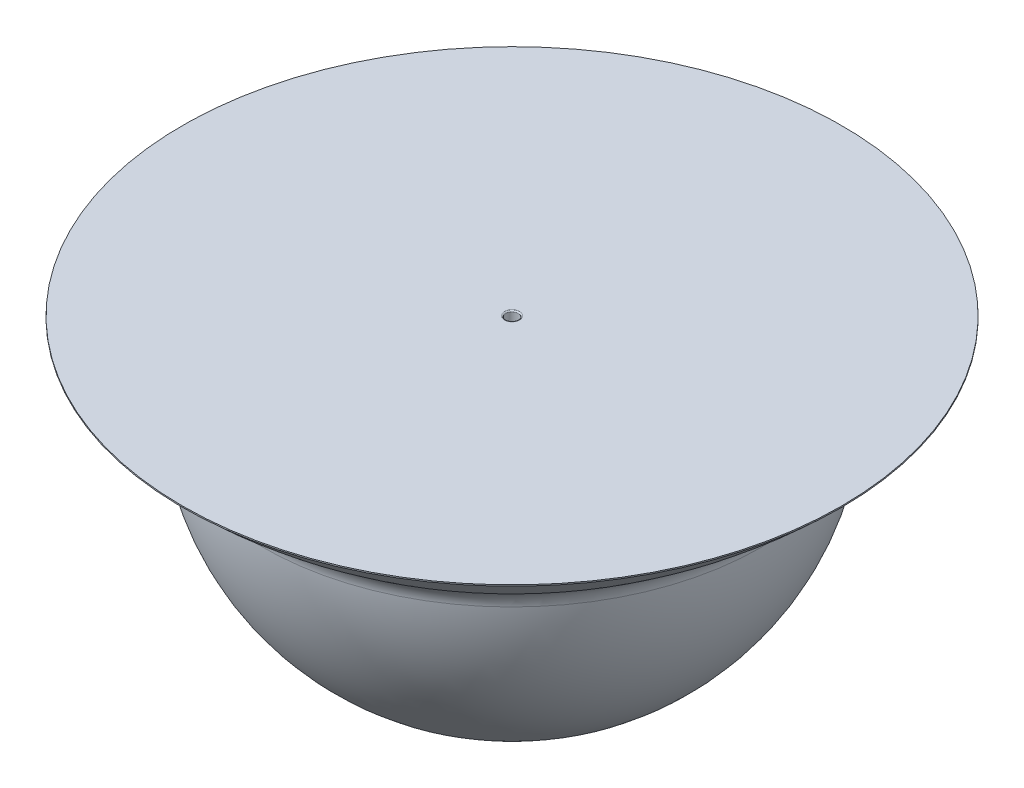
from build123d import *

# Parameters (mm, degrees)
FILLET1_R           = 20
SHELL1_T            = -1
SKETCH3_R           = 264.42717426
BOSS_EXTRUDE1_DEPTH = 1
SKETCH4_R           = 5
CUT_EXTRUDE1_DEPTH  = 451.38257191
SKETCH6_R           = 6
SKETCH6_R_2         = 5
BOSS_EXTRUDE2_DEPTH = 270
FILLET2_R           = 1


with BuildPart() as part:
    # Sketch2 → Revolve1 (revolve)
    with BuildSketch(Plane.XY):
        with BuildLine():
            Line((0, 50), (0, -200))
            ThreePointArc((0, -200), (141.421356237, -141.421356237), (200, 0))
            ThreePointArc((200, 0), (233.555453903, 23.270946312), (264.42717426, 50))
            Line((264.42717426, 50), (0, 50))
        make_face()
    revolve(axis=Axis((0, 50, 0), (0, -1, 0)))

    # Fillet1
    fillet1_edges = [part.edges().sort_by_distance(p)[0] for p in [
        (-200, 0, 0),
    ]]
    fillet(fillet1_edges, radius=FILLET1_R)

    # Shell1
    shell1_openings = [part.faces().sort_by_distance(p)[0] for p in [
        (0, 50, 0),
    ]]
    offset(amount=SHELL1_T, openings=shell1_openings, kind=Kind.INTERSECTION)

    # Sketch3 → Boss-Extrude1 (add)
    with BuildSketch(Plane(origin=(0, 50, 0), x_dir=(1, 0, 0), z_dir=(0, 1, 0))):
        Circle(SKETCH3_R)
    extrude(amount=BOSS_EXTRUDE1_DEPTH)

    # Sketch4 → Cut-Extrude1 (cut, through all)
    with BuildSketch(Plane(origin=(0, 51, 0), x_dir=(1, 0, 0), z_dir=(0, 1, 0))):
        with Locations(Location((0, 0, 0), (0, 0, 270))):
            Circle(SKETCH4_R)
    extrude(amount=-CUT_EXTRUDE1_DEPTH, mode=Mode.SUBTRACT)

    # Sketch6 → Boss-Extrude2 (add)
    with BuildSketch(Plane(origin=(0, 51, 0), x_dir=(1, 0, 0), z_dir=(0, 1, 0))):
        with Locations(Location((0, 0, 0), (0, 0, 270))):
            Circle(SKETCH6_R)
        with Locations(Location((0, 0, 0), (0, 0, 270))):
            Circle(SKETCH6_R_2, mode=Mode.SUBTRACT)
    extrude(amount=-BOSS_EXTRUDE2_DEPTH)

    # Fillet2
    fillet2_edges = [part.edges().sort_by_distance(p)[0] for p in [
        (0, 51, -5),
    ]]
    fillet(fillet2_edges, radius=FILLET2_R)


solid = part.part
